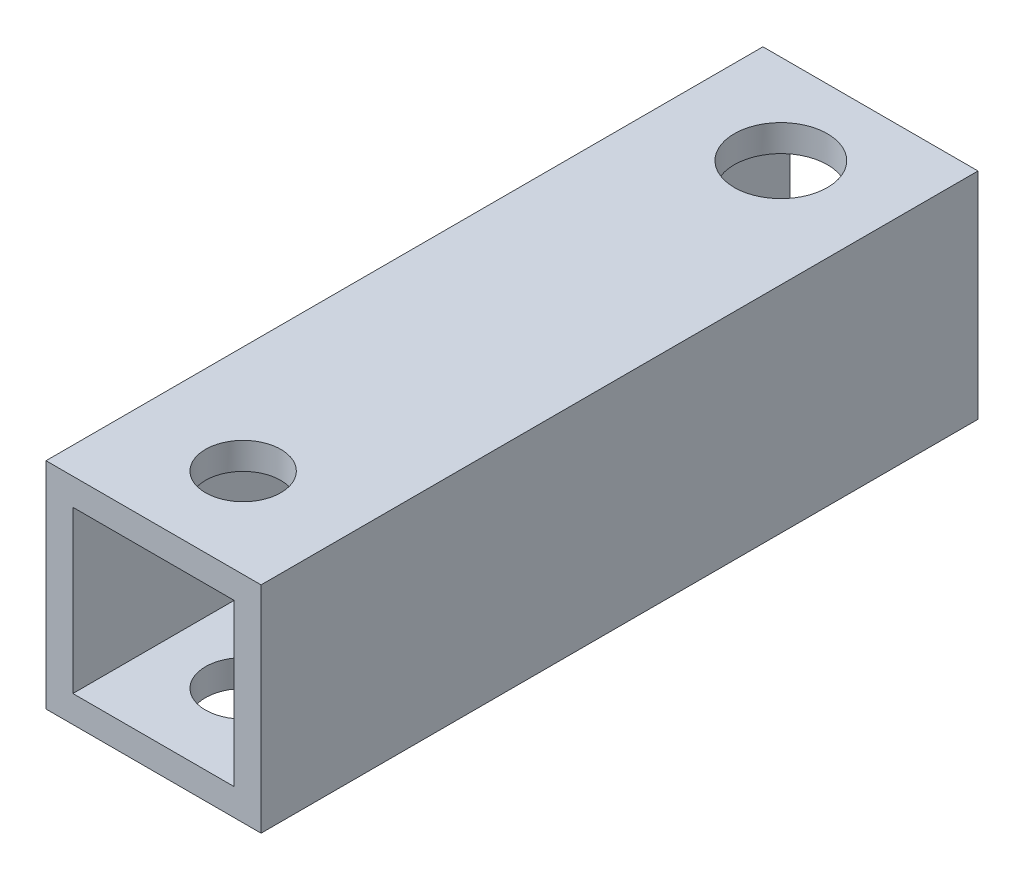
from build123d import *

# Parameters (mm, degrees)
SKETCH_1_W          = 12
SKETCH_1_H          = 12
SKETCH_1_W_2        = 9
SKETCH_1_H_2        = 9
EXTRUDE_1_DEPTH     = 40
SKETCH_2_R          = 2.6
SKETCH_2_R_2        = 2.1
CUT_EXTRUDE_1_DEPTH = 30


with BuildPart() as part:
    # ｽｹｯﾁ1 → ﾎﾞｽ - 押し出し1 (new body)
    with BuildSketch(Plane.XY):
        Rectangle(SKETCH_1_W, SKETCH_1_H)
        Rectangle(SKETCH_1_W_2, SKETCH_1_H_2, mode=Mode.SUBTRACT)
    extrude(amount=EXTRUDE_1_DEPTH)

    # ｽｹｯﾁ2 → ｶｯﾄ - 押し出し1 (cut)
    with BuildSketch(Plane(origin=(0, 6, 0), x_dir=(1, 0, 0), z_dir=(0, 1, 0))):
        with Locations((0, -5)):
            Circle(SKETCH_2_R)
        with Locations((0, -35)):
            Circle(SKETCH_2_R_2)
    extrude(amount=-CUT_EXTRUDE_1_DEPTH, mode=Mode.SUBTRACT)


solid = part.part
